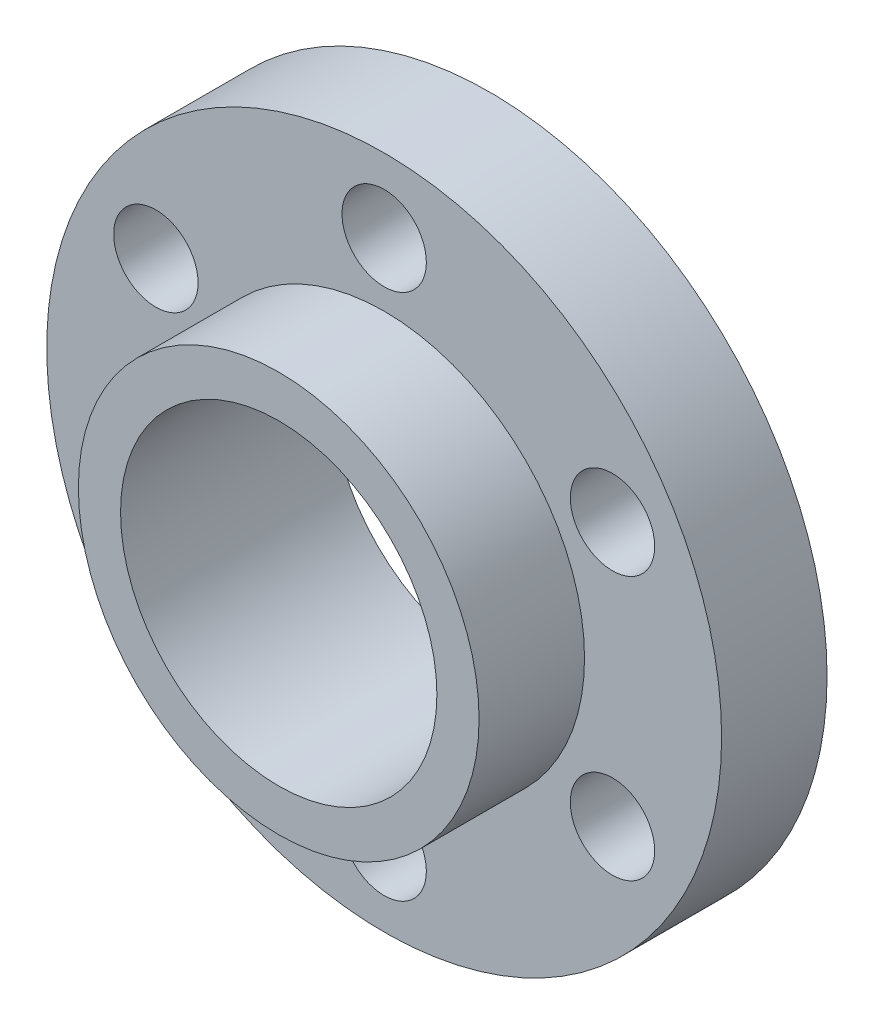
from build123d import *

# Parameters (mm, degrees)
SKETCH1_R           = 32
SKETCH1_R_2         = 15
BOSS_EXTRUDE1_DEPTH = 10
SKETCH2_R           = 19
SKETCH2_R_2         = 15
BOSS_EXTRUDE2_DEPTH = 10
SKETCH6_R           = 4
CUT_EXTRUDE1_DEPTH  = 11


with BuildPart() as part:
    # Sketch1 → Boss-Extrude1 (new body)
    with BuildSketch(Plane.XY):
        Circle(SKETCH1_R)
        Circle(SKETCH1_R_2, mode=Mode.SUBTRACT)
    extrude(amount=BOSS_EXTRUDE1_DEPTH)

    # Sketch2 → Boss-Extrude2 (add)
    with BuildSketch(Plane.XY.offset(10)):
        Circle(SKETCH2_R)
        Circle(SKETCH2_R_2, mode=Mode.SUBTRACT)
    extrude(amount=BOSS_EXTRUDE2_DEPTH)

    # Sketch6 → Cut-Extrude1 (cut, through all)
    with BuildSketch(Plane.XY.offset(10)):
        with Locations((-21.650635095, 12.5)):
            Circle(SKETCH6_R)
        with Locations((0, 25)):
            Circle(SKETCH6_R)
        with Locations((21.650635095, 12.5)):
            Circle(SKETCH6_R)
        with Locations((21.650635095, -12.5)):
            Circle(SKETCH6_R)
        with Locations((0, -25)):
            Circle(SKETCH6_R)
        with Locations((-21.650635095, -12.5)):
            Circle(SKETCH6_R)
    extrude(amount=-CUT_EXTRUDE1_DEPTH, mode=Mode.SUBTRACT)


solid = part.part
